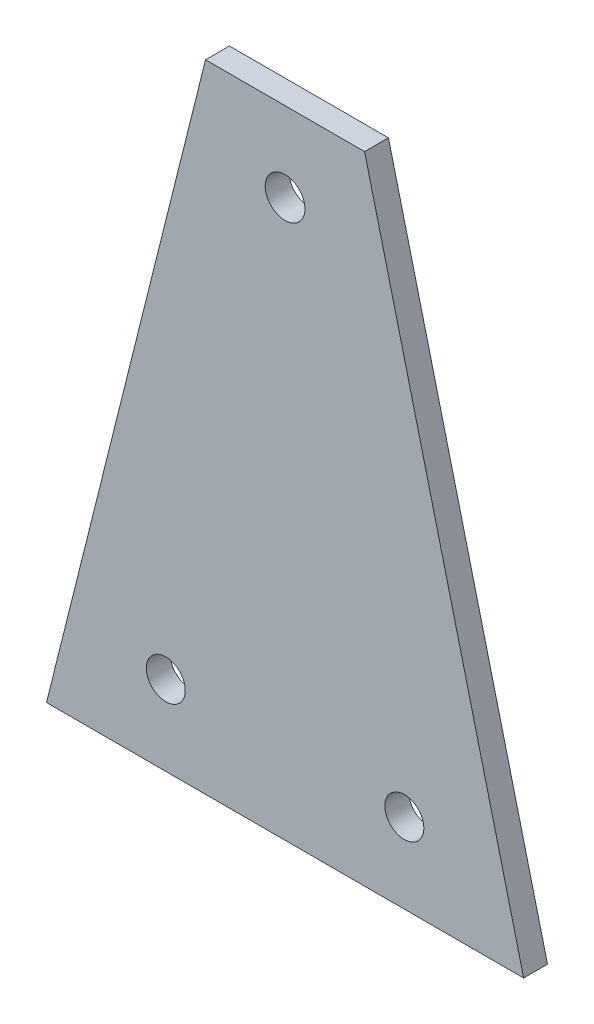
from build123d import *

# Parameters (mm, degrees)
SKETCH1_R           = 2.5
SKETCH1_R_2         = 2.45
BOSS_EXTRUDE1_DEPTH = 3


with BuildPart() as part:
    # Sketch1 → Boss-Extrude1 (new body)
    with BuildSketch(Plane.XY):
        Polygon((-10, 0), (10, 0), (30, -80), (-30, -80), align=None)
        with Locations((0, -10)):
            Circle(SKETCH1_R, mode=Mode.SUBTRACT)
        with Locations((15, -69.97)):
            Circle(SKETCH1_R_2, mode=Mode.SUBTRACT)
        with Locations((-15, -69.97)):
            Circle(SKETCH1_R_2, mode=Mode.SUBTRACT)
    extrude(amount=BOSS_EXTRUDE1_DEPTH)


solid = part.part
